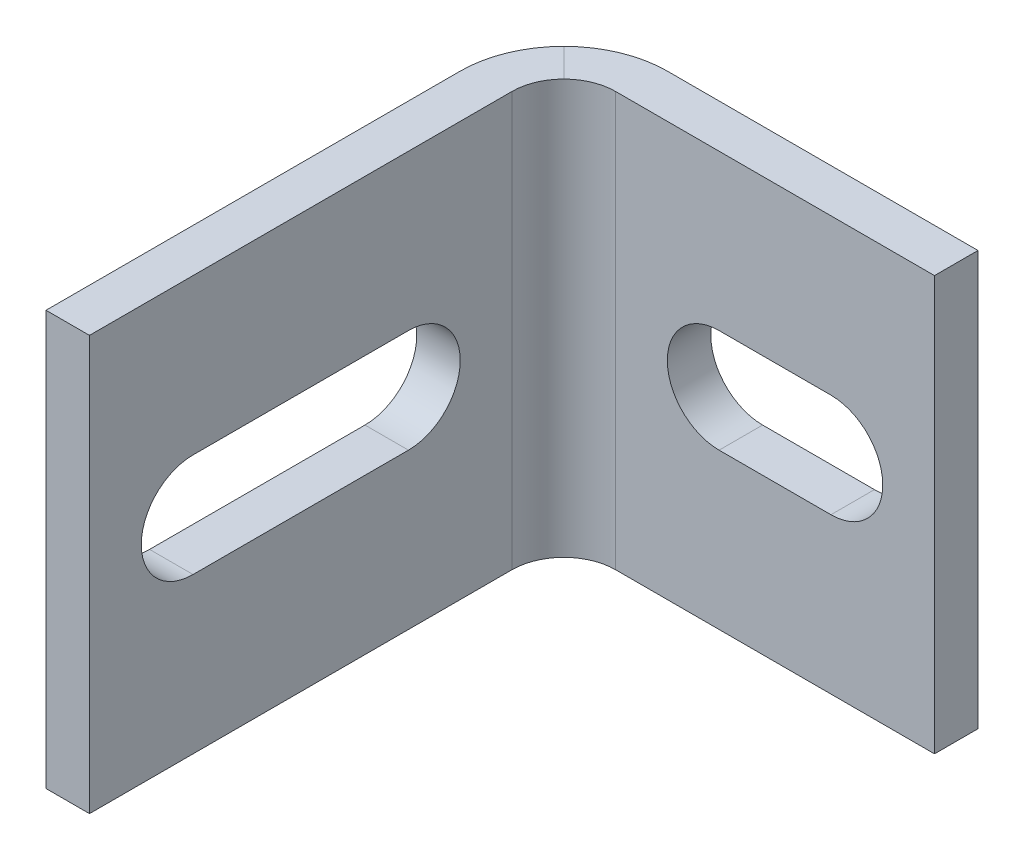
from build123d import *

# Parameters (mm, degrees)
SKETCH3_W          = 2.667
SKETCH3_H          = 25.4
FILLET1_R          = 3.175
FILLET2_R          = 6.35
CUT_EXTRUDE2_REACH = 27.4
CUT_EXTRUDE3_DEPTH = 3.667


with BuildPart() as part:
    # Sweep1: sweep along a path in Sketch4
    with BuildLine(Plane(origin=(0, 0, 0), x_dir=(1, 0, 0), z_dir=(0, 1, 0))) as sweep1_path:
        Line((0, 0), (0, 31.75))
        Line((0, 31.75), (25.4, 31.75))
    # Sketch3 → Sweep1 (sweep)
    with BuildSketch(Plane.XY):
        with Locations((1.3335, 0)):
            Rectangle(SKETCH3_W, SKETCH3_H)
    sweep(path=sweep1_path.line, transition=Transition.RIGHT)

    # Fillet1
    fillet1_edges = [part.edges().sort_by_distance(p)[0] for p in [
        (2.667, 0, -29.083),
    ]]
    fillet(fillet1_edges, radius=FILLET1_R)

    # Fillet2
    fillet2_edges = [part.edges().sort_by_distance(p)[0] for p in [
        (0, 0, -31.75),
    ]]
    fillet(fillet2_edges, radius=FILLET2_R)

    # Sketch6 → Cut-Extrude2 (cut, up to next)
    with BuildSketch(Plane(origin=(0, 0, 0), x_dir=(0, 0, -1), z_dir=(1, 0, 0)), mode=Mode.PRIVATE) as cut_extrude2_sk1:
        with BuildLine():
            Line((19.558, -3.175), (6.35, -3.175))
            ThreePointArc((6.35, -3.175), (3.175, 0), (6.35, 3.175))
            Line((6.35, 3.175), (19.558, 3.175))
            ThreePointArc((19.558, 3.175), (22.733, 0), (19.558, -3.175))
        make_face()
    cut_extrude2_tool1 = extrude(cut_extrude2_sk1.sketch, amount=CUT_EXTRUDE2_REACH, mode=Mode.PRIVATE) & part.part
    add(cut_extrude2_tool1.solids().sort_by_distance((0, 0, -12.954))[0], mode=Mode.SUBTRACT)

    # Sketch7 → Cut-Extrude3 (cut, through all)
    with BuildSketch(Plane.XY.offset(-29.083)):
        with BuildLine():
            Line((12.192, 3.175), (19.05, 3.175))
            ThreePointArc((19.05, 3.175), (22.225, 0), (19.05, -3.175))
            Line((19.05, -3.175), (12.192, -3.175))
            ThreePointArc((12.192, -3.175), (9.017, 0), (12.192, 3.175))
        make_face()
    extrude(amount=-CUT_EXTRUDE3_DEPTH, mode=Mode.SUBTRACT)


solid = part.part
